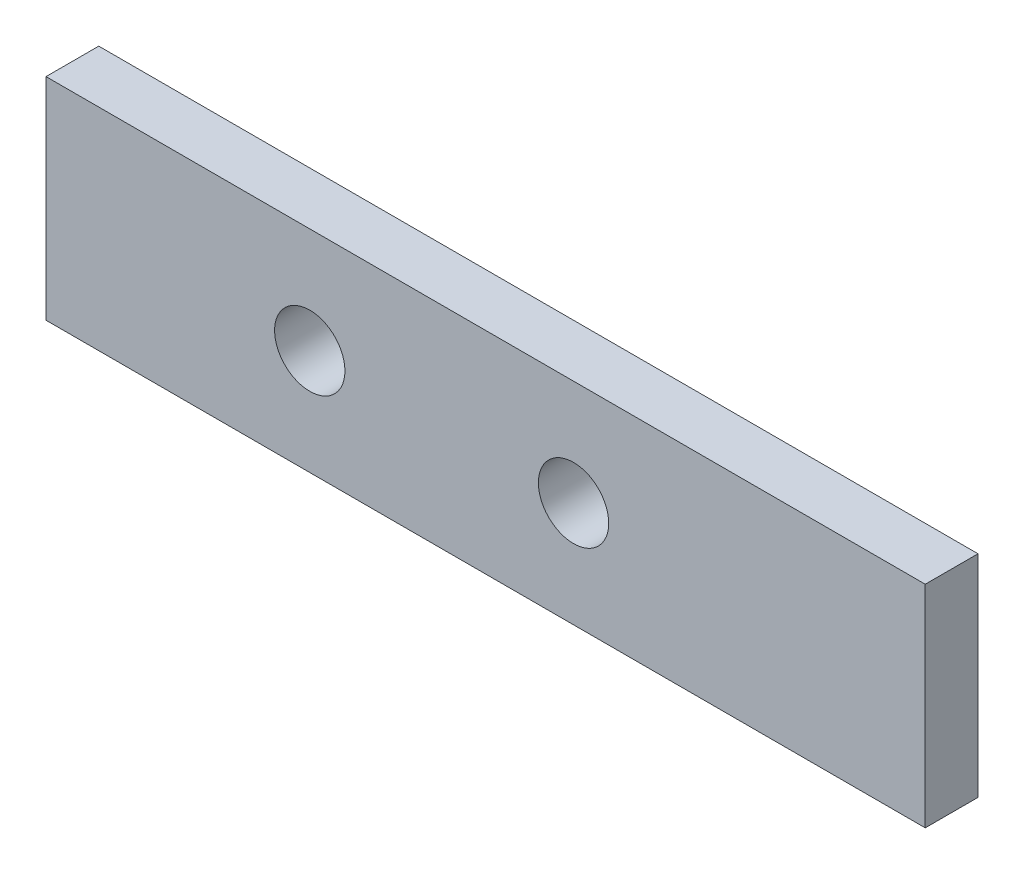
from build123d import *

# Parameters (mm, degrees)
PLAT_W                      = 60
PLAT_H                      = 15
EL_MENT_M_CANO_SOUD_1_DEPTH = 250
ESQUISSE2_R                 = 10
ENL_V_MAT_EXTRU_1_DEPTH     = 16


with BuildPart() as part:
    # plat → Elément mécano-soudé1 (new body)
    with BuildSketch(Plane.YZ):
        Rectangle(PLAT_W, PLAT_H)
    extrude(amount=EL_MENT_M_CANO_SOUD_1_DEPTH)

    # Esquisse2 → Enlèv. mat.-Extru.1 (cut, through all)
    with BuildSketch(Plane.XY.offset(7.5)):
        with Locations((150, 0)):
            Circle(ESQUISSE2_R)
        with Locations((75, 0)):
            Circle(ESQUISSE2_R)
    extrude(amount=-ENL_V_MAT_EXTRU_1_DEPTH, mode=Mode.SUBTRACT)


solid = part.part
